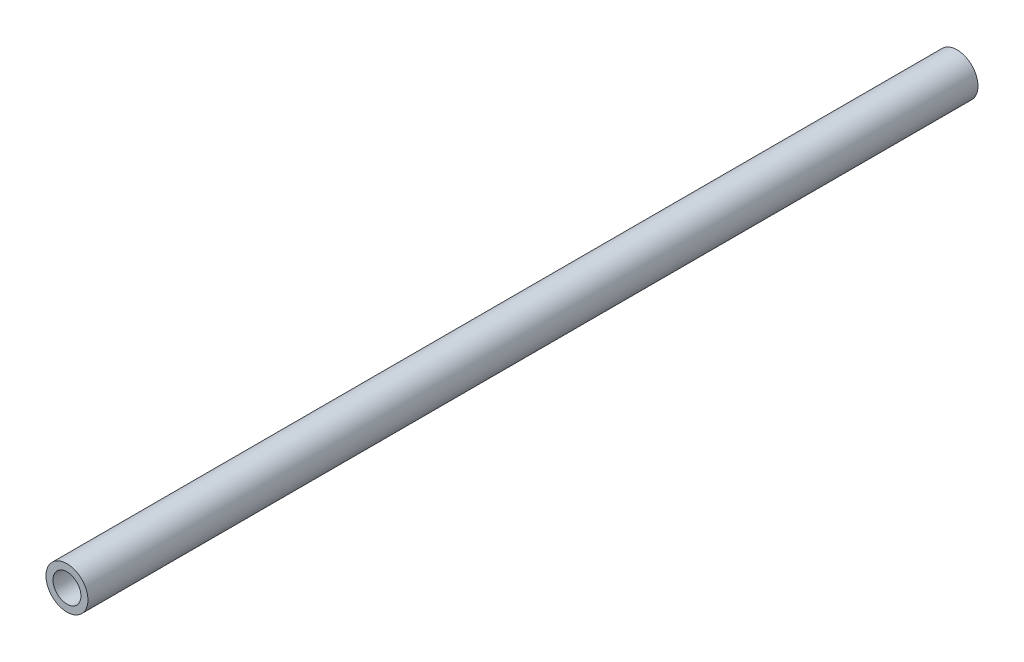
from build123d import *

# Parameters (mm, degrees)
SKETCH1_R           = 3
SKETCH1_R_2         = 2
BOSS_EXTRUDE1_DEPTH = 127.28


with BuildPart() as part:
    # Sketch1 → Boss-Extrude1 (new body)
    with BuildSketch(Plane.XY):
        Circle(SKETCH1_R)
        Circle(SKETCH1_R_2, mode=Mode.SUBTRACT)
    extrude(amount=BOSS_EXTRUDE1_DEPTH)


solid = part.part
